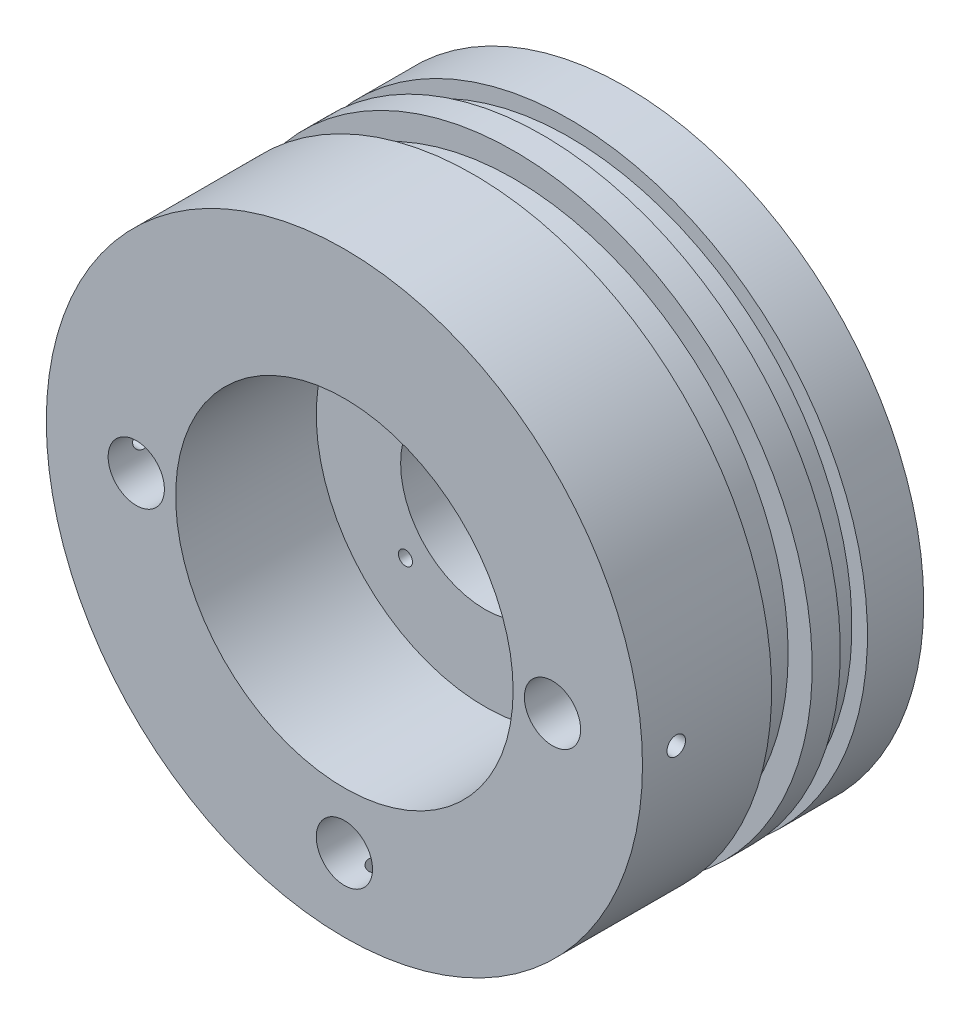
from build123d import *

# Parameters (mm, degrees)
SKETCH1_R                      = 53
BOSS_EXTRUDE1_DEPTH            = 50
F_10_0_10_DIAMETER_HOLE1_D     = 10
F_10_0_10_DIAMETER_HOLE1_DEPTH = 17.5
F_10_0_10_DIAMETER_HOLE1_TIP   = 3.004303095
M4_TAPPED_HOLE1_REACH          = 130.627
M4_TAPPED_HOLE1_BORE_R         = 1.65
CIRPATTERN1_COUNT              = 3
CIRPATTERN1_ANGLE              = 180
SKETCH11_R                     = 30
CUT_EXTRUDE2_DEPTH             = 25
SKETCH12_W                     = 4.826
SKETCH12_H                     = 2.76515
SKETCH12_W_2                   = 7.2136
SKETCH12_H_2                   = 4.27264
SKETCH14_W                     = 2.667
SKETCH14_H                     = 4.572
CUT_EXTRUDE3_REACH             = 92.1
SKETCH15_R                     = 15
CIRPATTERN2_COUNT              = 8
CIRPATTERN3_COUNT              = 4


with BuildPart() as part:
    # Sketch1 → Boss-Extrude1 (new body)
    with BuildSketch(Plane.XY):
        Circle(SKETCH1_R)
    extrude(amount=BOSS_EXTRUDE1_DEPTH)

    # Ø10.0 (10) Diameter Hole1
    with Locations(Plane.XY.offset(50)):
        with Locations((-37, 0), (37, 0), (0, -40)):
            Hole(F_10_0_10_DIAMETER_HOLE1_D / 2, depth=F_10_0_10_DIAMETER_HOLE1_DEPTH)
            with Locations((0, 0, -(F_10_0_10_DIAMETER_HOLE1_DEPTH + F_10_0_10_DIAMETER_HOLE1_TIP / 2))):  # 118° drill point
                Cone(0, F_10_0_10_DIAMETER_HOLE1_D / 2, F_10_0_10_DIAMETER_HOLE1_TIP, mode=Mode.SUBTRACT)

    # M4 Tapped Hole1 bore → M4 Tapped Hole1 (cut, up to next)
    with BuildSketch(Plane.ZY.offset(53), mode=Mode.PRIVATE) as m4_tapped_hole1_sk1:
        with Locations((44, 0)):
            Circle(M4_TAPPED_HOLE1_BORE_R)
    m4_tapped_hole1_tool1 = extrude(m4_tapped_hole1_sk1.sketch, amount=-M4_TAPPED_HOLE1_REACH, mode=Mode.PRIVATE) & part.part
    m4_tapped_hole1 = m4_tapped_hole1_tool1.solids().sort_by_distance((-53, 0, 44))[0]
    add(m4_tapped_hole1, mode=Mode.SUBTRACT)

    # CirPattern1: M4 Tapped Hole1 ×3 about axis
    cirpattern1_axis = Axis((0, 0, 50), (0, 0, 1))
    for i in range(1, CIRPATTERN1_COUNT):
        add(m4_tapped_hole1.rotate(cirpattern1_axis, i * CIRPATTERN1_ANGLE / (CIRPATTERN1_COUNT - 1)), mode=Mode.SUBTRACT)

    # Sketch11 → Cut-Extrude2 (cut)
    with BuildSketch(Plane.XY.offset(50)):
        Circle(SKETCH11_R)
    extrude(amount=-CUT_EXTRUDE2_DEPTH, mode=Mode.SUBTRACT)

    # Sketch12 → Cut-Revolve1 (revolve, cut)
    with BuildSketch(Plane(origin=(0, 0, 0), x_dir=(0, 0, -1), z_dir=(1, 0, 0)), mode=Mode.PRIVATE) as cut_revolve1_sk:
        with Locations((-12.413, 51.617425)):
            Rectangle(SKETCH12_W, SKETCH12_H)
        with Locations((-23.4328, 50.86368)):
            Rectangle(SKETCH12_W_2, SKETCH12_H_2)
    revolve(cut_revolve1_sk.sketch.rotate(Axis((0, 0, 0), (0, 0, 1)), 90), axis=Axis((0, 0, 0), (0, 0, 1)), mode=Mode.SUBTRACT)

    # Sketch14 → Cut-Revolve2 (revolve, cut)
    with BuildSketch(Plane(origin=(0, 0, 0), x_dir=(0, 0, -1), z_dir=(1, 0, 0)), mode=Mode.PRIVATE) as cut_revolve2_sk:
        with Locations((-1.3335, 24.8666)):
            Rectangle(SKETCH14_W, SKETCH14_H)
    revolve(cut_revolve2_sk.sketch.rotate(Axis((0, 0, 0), (0, 0, -1)), 270), axis=Axis((0, 0, 0), (0, 0, -1)), mode=Mode.SUBTRACT)

    # Sketch15 → Cut-Extrude3 (cut, up to next)
    with BuildSketch(Plane(origin=(0, 0, 0), x_dir=(-1, 0, 0), z_dir=(0, 0, -1)), mode=Mode.PRIVATE) as cut_extrude3_sk1:
        Circle(SKETCH15_R)
    cut_extrude3_tool1 = extrude(cut_extrude3_sk1.sketch, amount=-CUT_EXTRUDE3_REACH, mode=Mode.PRIVATE) & part.part
    add(cut_extrude3_tool1.solids().sort_by_distance((0, 0, 0))[0], mode=Mode.SUBTRACT)

    # Sketch17 → M5 Tapped Hole1 (revolve, cut)
    with BuildSketch(Plane(origin=(-28.284271247, 28.284271247, 0), x_dir=(0, 1, 0), z_dir=(1, 0, 0))):
        Polygon((0, 0), (0, 15.2618073), (2.1, 14), (2.1, 0), align=None)
    m5_tapped_hole1 = revolve(axis=Axis((-28.284271247, 28.284271247, -6.35), (0, 0, 1)), mode=Mode.SUBTRACT)

    # CirPattern2: M5 Tapped Hole1 ×8 about axis
    cirpattern2_axis = Axis((0, 0, 0), (0, 0, 1))
    for i in range(1, CIRPATTERN2_COUNT):
        add(m5_tapped_hole1.rotate(cirpattern2_axis, i * 360 / CIRPATTERN2_COUNT), mode=Mode.SUBTRACT)

    # Sketch19 → M3 Tapped Hole1 (revolve, cut)
    with BuildSketch(Plane(origin=(14.142135624, 14.142135624, 25), x_dir=(0, -1, 0), z_dir=(1, 0, 0))):
        Polygon((0, 0), (0, 8.251075774), (1.25, 7.5), (1.25, 0), align=None)
    m3_tapped_hole1 = revolve(axis=Axis((14.142135624, 14.142135624, 31.35), (0, 0, -1)), mode=Mode.SUBTRACT)

    # CirPattern3: M3 Tapped Hole1 ×4 about axis
    cirpattern3_axis = Axis((0, 0, 0), (0, 0, 1))
    for i in range(1, CIRPATTERN3_COUNT):
        add(m3_tapped_hole1.rotate(cirpattern3_axis, i * 360 / CIRPATTERN3_COUNT), mode=Mode.SUBTRACT)


solid = part.part
